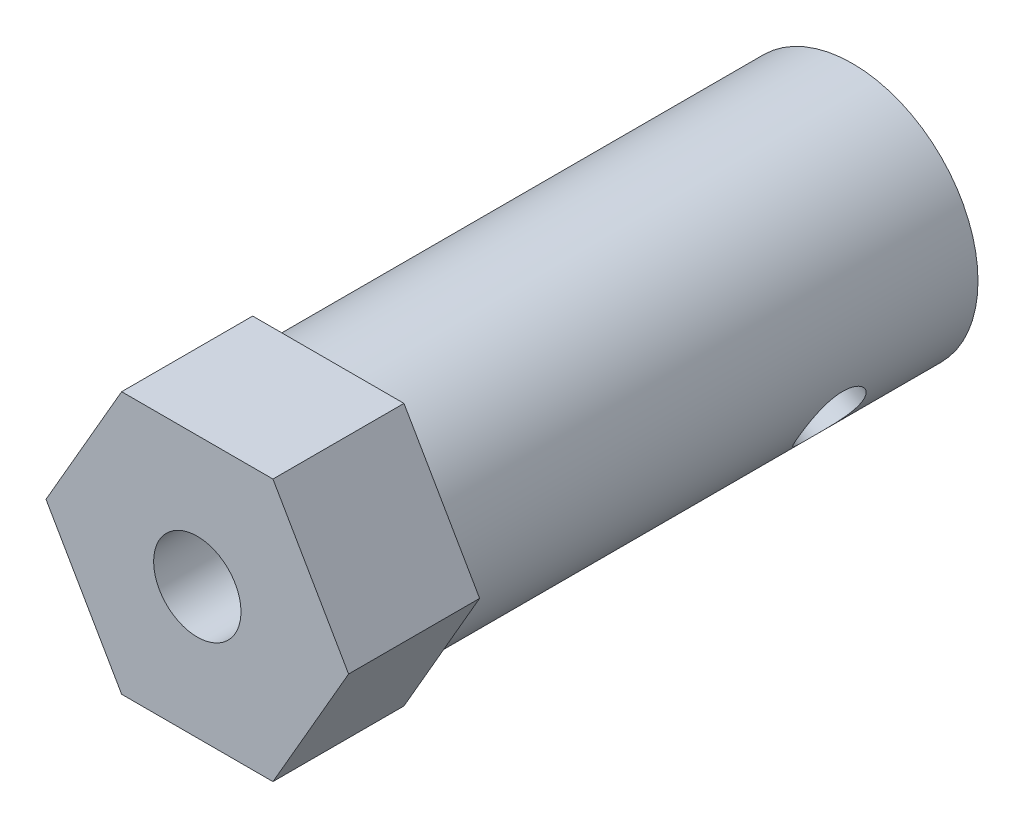
from build123d import *

# Parameters (mm, degrees)
BOSS_EXTRUDE1_DEPTH = 6
SKETCH2_R           = 5.75
BOSS_EXTRUDE2_DEPTH = 24
SKETCH4_R           = 2
CUT_EXTRUDE2_DEPTH  = 31
SKETCH5_R           = 1.5
CUT_EXTRUDE3_DEPTH  = 6


with BuildPart() as part:
    # Sketch1 → Boss-Extrude1 (new body)
    with BuildSketch(Plane(origin=(0, 0, 0), x_dir=(0, 1, 0), z_dir=(0, 0, 1))):
        Polygon((0, 6.92820323), (-6, 3.464101615), (-6, -3.464101615), (0, -6.92820323), (6, -3.464101615), (6, 3.464101615), align=None)
    extrude(amount=BOSS_EXTRUDE1_DEPTH)

    # Sketch2 → Boss-Extrude2 (add)
    with BuildSketch(Plane(origin=(0, 0, 0), x_dir=(1, 0, 0), z_dir=(0, 0, -1))):
        Circle(SKETCH2_R)
    extrude(amount=BOSS_EXTRUDE2_DEPTH)

    # Sketch4 → Cut-Extrude2 (cut, through all)
    with BuildSketch(Plane(origin=(0, 0, -24), x_dir=(1, 0, 0), z_dir=(0, 0, -1))):
        Circle(SKETCH4_R)
    extrude(amount=-CUT_EXTRUDE2_DEPTH, mode=Mode.SUBTRACT)

    # Sketch5 → Cut-Extrude3 (cut)
    with BuildSketch(Plane(origin=(5.196152423, -3, 0), x_dir=(0.5, 0.866025404, 0), z_dir=(0.866025404, -0.5, 0))):
        with Locations((0, -18)):
            Circle(SKETCH5_R)
    extrude(amount=-CUT_EXTRUDE3_DEPTH, mode=Mode.SUBTRACT)


solid = part.part
